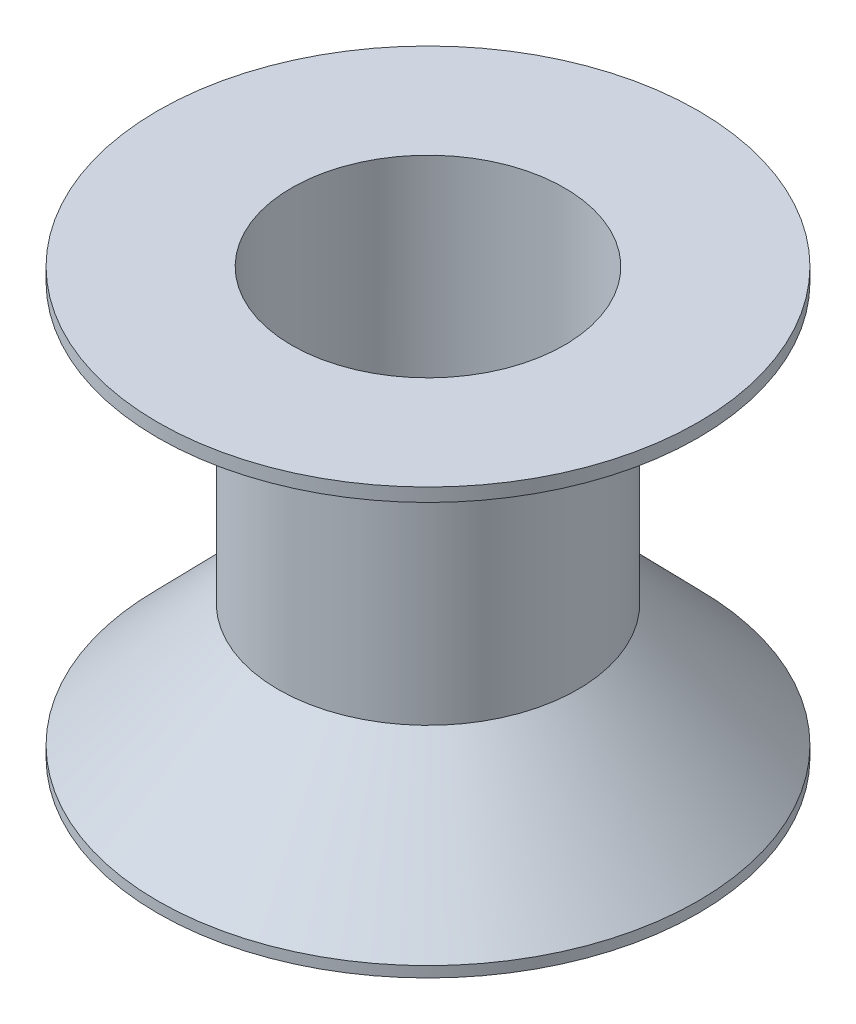
from build123d import *

# Parameters (mm, degrees)
CUT_EXTRUDE1_REACH = 161
SKETCH2_R          = 51


with BuildPart() as part:
    # Sketch1 → Revolve1 (revolve)
    with BuildSketch(Plane.XY):
        Polygon((50, 159), (0, 159), (0, 154), (45, 154), (45, 50), (0, 4), (0, 0), (10.27, 0), (10.27, 4), (19.87, 4), (19.87, 0), (30.14, 0), (30.14, 4), (39.74, 4), (39.74, 0), (50, 0), (101, 0), (101, 4), (50, 4), align=None)
    revolve(axis=Axis((101, 4, 0), (0, -1, 0)))

    # Sketch2 → Cut-Extrude1 (cut, up to next)
    with BuildSketch(Plane.XZ, mode=Mode.PRIVATE) as cut_extrude1_sk1:
        with Locations((101, 0)):
            Circle(SKETCH2_R)
    cut_extrude1_tool1 = extrude(cut_extrude1_sk1.sketch, amount=-CUT_EXTRUDE1_REACH, mode=Mode.PRIVATE) & part.part
    add(cut_extrude1_tool1.solids().sort_by_distance((101, 0, 0))[0], mode=Mode.SUBTRACT)


solid = part.part
